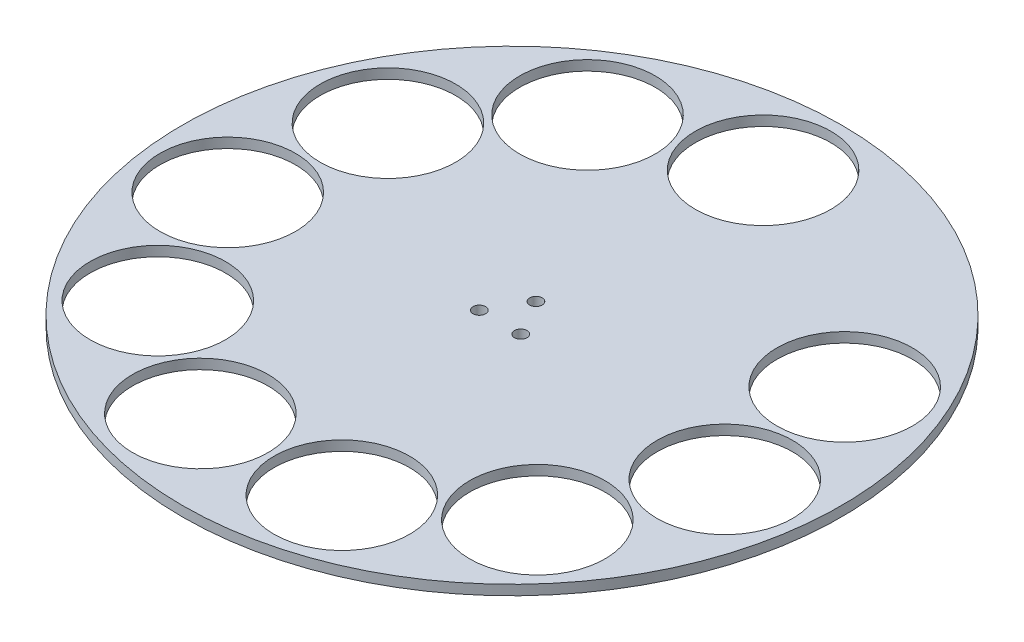
from build123d import *

# Parameters (mm, degrees)
SKETCH2_R           = 105
SKETCH2_R_2         = 21.59
SKETCH2_R_3         = 2
BOSS_EXTRUDE2_DEPTH = 3.175


with BuildPart() as part:
    # Sketch2 → Boss-Extrude2 (new body)
    with BuildSketch(Plane(origin=(0, 0, 0), x_dir=(1, 0, 0), z_dir=(0, 1, 0))):
        Circle(SKETCH2_R)
        with Locations((0, 80)):
            Circle(SKETCH2_R_2, mode=Mode.SUBTRACT)
        with Locations((72.770559628, 33.23320104)):
            Circle(SKETCH2_R_2, mode=Mode.SUBTRACT)
        with Locations((79.18571535, -11.385187062)):
            Circle(SKETCH2_R_2, mode=Mode.SUBTRACT)
        with Locations((60.459965948, -52.388858716)):
            Circle(SKETCH2_R_2, mode=Mode.SUBTRACT)
        with Locations((22.538604547, -76.759437889)):
            Circle(SKETCH2_R_2, mode=Mode.SUBTRACT)
        with Locations((-22.538604547, -76.759437889)):
            Circle(SKETCH2_R_2, mode=Mode.SUBTRACT)
        with Locations((-60.459965948, -52.388858716)):
            Circle(SKETCH2_R_2, mode=Mode.SUBTRACT)
        with Locations((-79.18571535, -11.385187062)):
            Circle(SKETCH2_R_2, mode=Mode.SUBTRACT)
        with Locations((-72.770559628, 33.23320104)):
            Circle(SKETCH2_R_2, mode=Mode.SUBTRACT)
        with Locations((-43.251265396, 67.300282626)):
            Circle(SKETCH2_R_2, mode=Mode.SUBTRACT)
        with Locations((0, 7.62)):
            Circle(SKETCH2_R_3, mode=Mode.SUBTRACT)
        with Locations((6.599113577, -3.81)):
            Circle(SKETCH2_R_3, mode=Mode.SUBTRACT)
        with Locations((-6.599113577, -3.81)):
            Circle(SKETCH2_R_3, mode=Mode.SUBTRACT)
    extrude(amount=BOSS_EXTRUDE2_DEPTH)


solid = part.part
